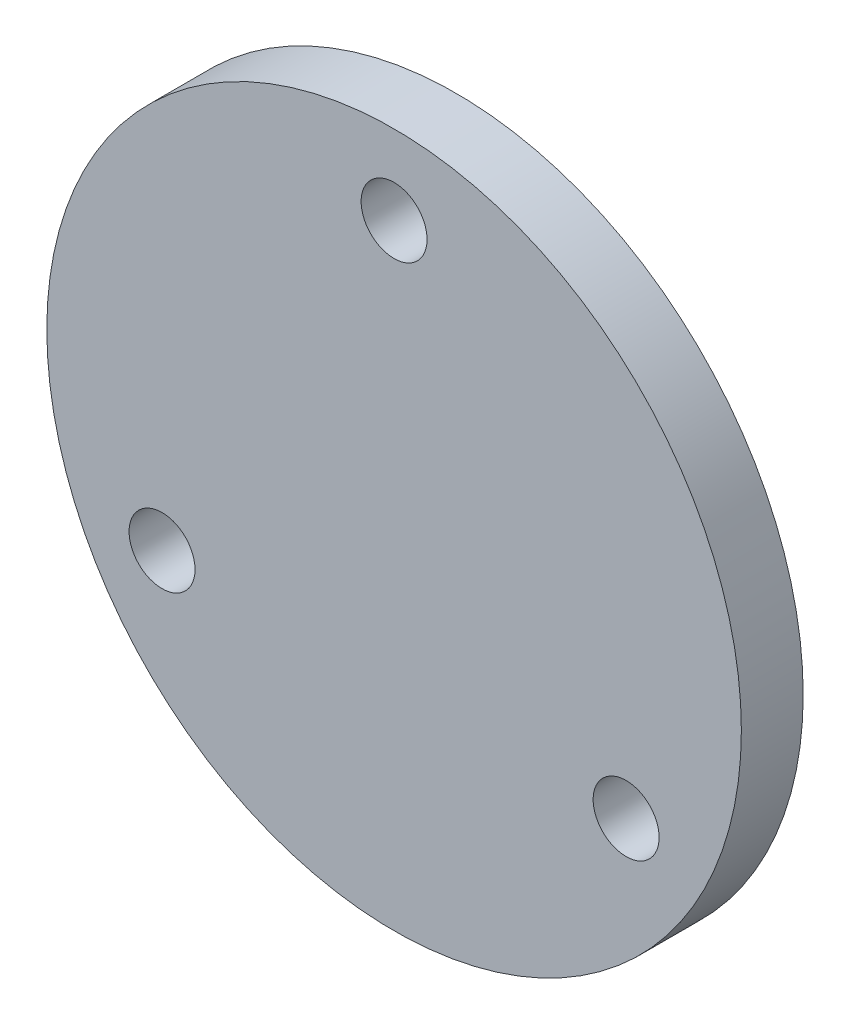
from build123d import *

# Parameters (mm, degrees)
SKETCH_1_R      = 16.85
SKETCH_1_R_2    = 1.6
EXTRUDE_1_DEPTH = 3


with BuildPart() as part:
    # 草图1 → 凸台-拉伸1 (new body)
    with BuildSketch(Plane.XY):
        Circle(SKETCH_1_R)
        with Locations((0, 13)):
            Circle(SKETCH_1_R_2, mode=Mode.SUBTRACT)
        with Locations((11.258330249, -6.5)):
            Circle(SKETCH_1_R_2, mode=Mode.SUBTRACT)
        with Locations((-11.258330249, -6.5)):
            Circle(SKETCH_1_R_2, mode=Mode.SUBTRACT)
    extrude(amount=EXTRUDE_1_DEPTH)


solid = part.part
